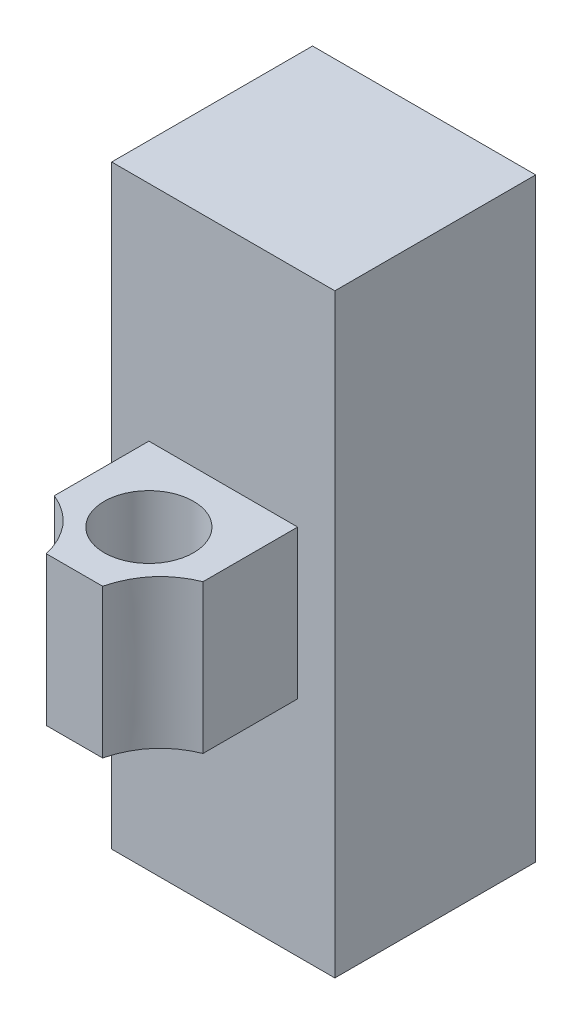
from build123d import *

# Parameters (mm, degrees)
SKETCH1_W           = 20
SKETCH1_H           = 20
BOSS_EXTRUDE1_DEPTH = 20
SKETCH2_R           = 6
CUT_EXTRUDE1_DEPTH  = 21
CUT_EXTRUDE2_DEPTH  = 21
SKETCH4_W           = 30
SKETCH4_H           = 80
BOSS_EXTRUDE2_DEPTH = 27


with BuildPart() as part:
    # Sketch1 → Boss-Extrude1 (new body)
    with BuildSketch(Plane.XY):
        Rectangle(SKETCH1_W, SKETCH1_H)
    extrude(amount=BOSS_EXTRUDE1_DEPTH)

    # Sketch2 → Cut-Extrude1 (cut, through all)
    with BuildSketch(Plane(origin=(0, 10, 0), x_dir=(1, 0, 0), z_dir=(0, 1, 0))):
        with Locations((0, -10)):
            Circle(SKETCH2_R)
    extrude(amount=-CUT_EXTRUDE1_DEPTH, mode=Mode.SUBTRACT)

    # Sketch3 → Cut-Extrude2 (cut, through all)
    with BuildSketch(Plane(origin=(0, 10, 0), x_dir=(1, 0, 0), z_dir=(0, 1, 0))):
        with BuildLine():
            Line((-10, -12.714318114), (-10, -20))
            Line((-10, -20), (-3.788282588, -20))
            add(Edge.make_bspline(
                [(-10, -12.714318114), (-5.112714727, -14.756625636), (-3.788282588, -20)],
                knots=[0, 0, 0, 1, 1, 1], degree=2))
        make_face()
        with BuildLine():
            Line((10, -12.714318114), (10, -20))
            Line((10, -20), (3.788282588, -20))
            add(Edge.make_bspline(
                [(10, -12.714318114), (5.112714727, -14.756625636), (3.788282588, -20)],
                knots=[0, 0, 0, 1, 1, 1], degree=2))
        make_face()
    extrude(amount=-CUT_EXTRUDE2_DEPTH, mode=Mode.SUBTRACT)

    # Sketch4 → Boss-Extrude2 (add)
    with BuildSketch(Plane(origin=(0, 0, 0), x_dir=(-1, 0, 0), z_dir=(0, 0, -1))):
        Rectangle(SKETCH4_W, SKETCH4_H)
    extrude(amount=BOSS_EXTRUDE2_DEPTH)


solid = part.part
